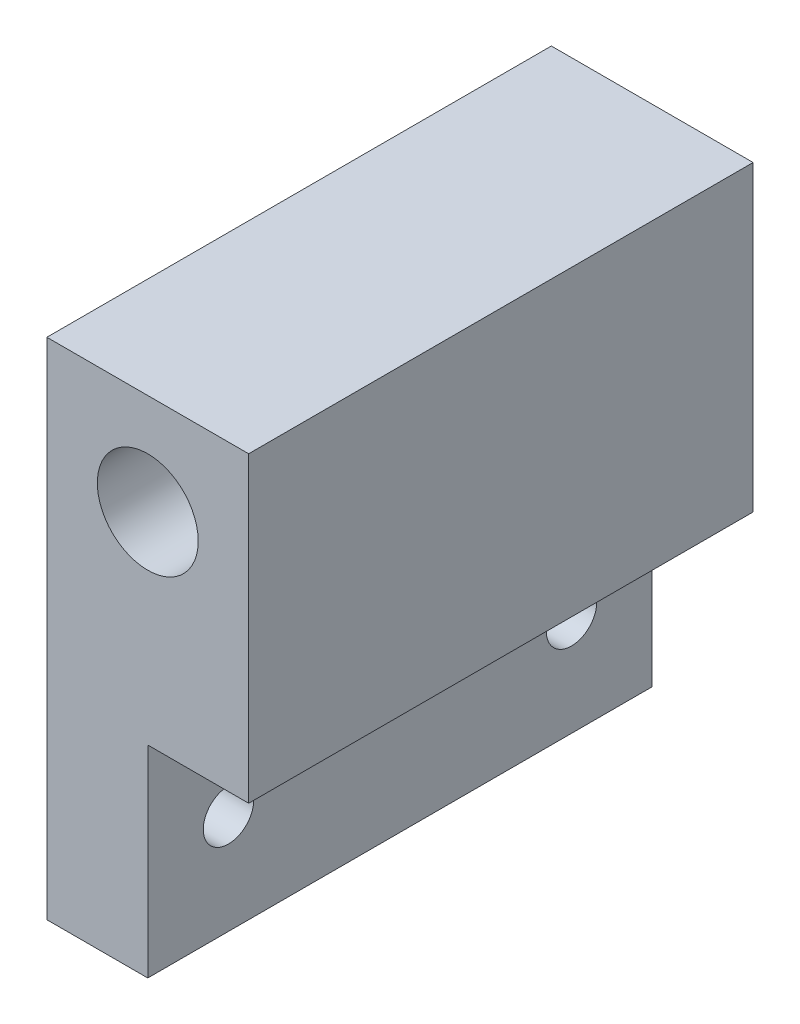
from build123d import *

# Parameters (mm, degrees)
ESQUISSE1_W             = 20
ESQUISSE1_H             = 20
ESQUISSE1_R             = 5
ESQUISSE1_H_2           = 30
BOSS_EXTRU_1_DEPTH      = 15
ESQUISSE2_W             = 20
ESQUISSE2_H             = 50
ESQUISSE2_R             = 5
BOSS_EXTRU_2_DEPTH      = 35
ESQUISSE3_R             = 2.5
ENL_V_MAT_EXTRU_1_DEPTH = 30
ESQUISSE4_W             = 50
ESQUISSE4_H             = 20
ENL_V_MAT_EXTRU_2_DEPTH = 10


with BuildPart() as part:
    # Esquisse1 → Boss.-Extru.1 (new body)
    with BuildSketch(Plane.XY):
        Rectangle(ESQUISSE1_W, ESQUISSE1_H)
        Circle(ESQUISSE1_R, mode=Mode.SUBTRACT)
        with Locations((0, -25)):
            Rectangle(ESQUISSE1_W, ESQUISSE1_H_2)
    extrude(amount=BOSS_EXTRU_1_DEPTH)

    # Esquisse2 → Boss.-Extru.2 (add)
    with BuildSketch(Plane.XY.offset(15)):
        with Locations((0, -15)):
            Rectangle(ESQUISSE2_W, ESQUISSE2_H)
        Circle(ESQUISSE2_R, mode=Mode.SUBTRACT)
    extrude(amount=BOSS_EXTRU_2_DEPTH)

    # Esquisse3 → Enlèv. mat.-Extru.1 (cut)
    with BuildSketch(Plane(origin=(10, 0, 0), x_dir=(0, 0, -1), z_dir=(1, 0, 0))):
        with Locations((-42, -30)):
            Circle(ESQUISSE3_R)
        with Locations((-8, -30)):
            Circle(ESQUISSE3_R)
    extrude(amount=-ENL_V_MAT_EXTRU_1_DEPTH, mode=Mode.SUBTRACT)

    # Esquisse4 → Enlèv. mat.-Extru.2 (cut)
    with BuildSketch(Plane(origin=(10, 0, 0), x_dir=(0, 0, -1), z_dir=(1, 0, 0))):
        with Locations((-25, -30)):
            Rectangle(ESQUISSE4_W, ESQUISSE4_H)
    extrude(amount=-ENL_V_MAT_EXTRU_2_DEPTH, mode=Mode.SUBTRACT)


solid = part.part
